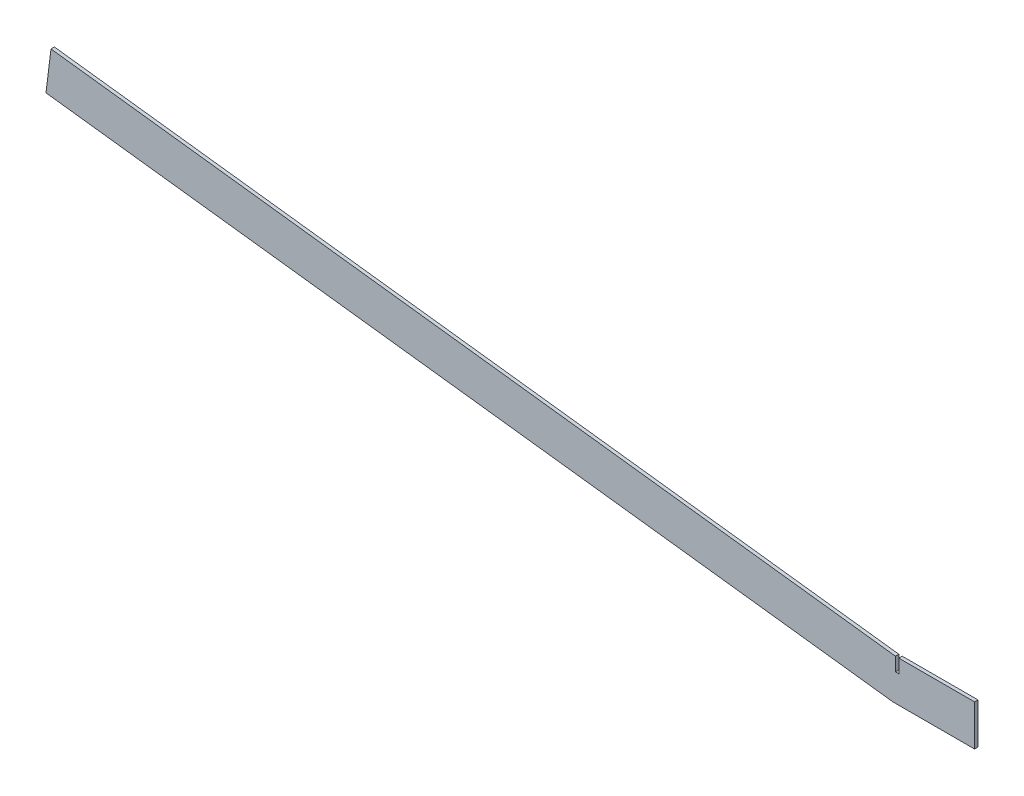
from build123d import *

# Parameters (mm, degrees)
BOSS_EXTRUDE1_DEPTH = 1.5875


with BuildPart() as part:
    # Sketch1 → Boss-Extrude1 (new body, symmetric)
    with BuildSketch(Plane.XY):
        Polygon((-789.745040533, 96.968498027), (0, 0), (76.2, 0), (76.2, 38.1), (5.505295828, 38.1), (5.505295828, 25.4), (2.330295828, 25.4), (2.330295828, 38.1), (-785.101818549, 134.784506405), align=None)
    extrude(amount=BOSS_EXTRUDE1_DEPTH, both=True)


solid = part.part
